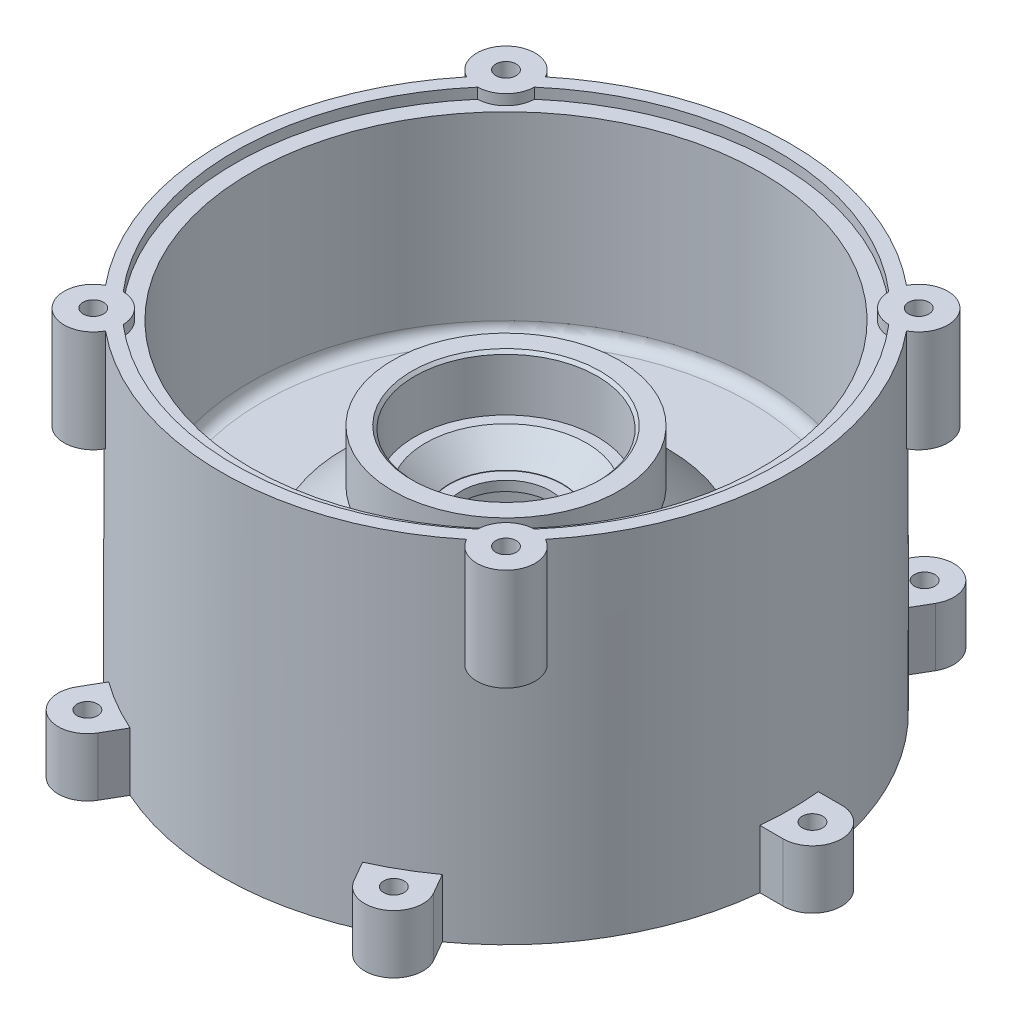
from build123d import *

# Parameters (mm, degrees)
ESBO_O4_R                = 10
RESSALTO_EXTRUS_O1_DEPTH = 35
RESSALTO_EXTRUS_O2_DEPTH = 20
ESBO_O8_R                = 3.5
CORTE_EXTRUS_O2_DEPTH    = 20
PADR_OCIRCULAR1_COUNT    = 6
ESBO_O6_R                = 3.5
CORTE_EXTRUS_O1_DEPTH    = 15
ESBO_O9_R                = 1.25
CORTE_EXTRUS_O3_DEPTH    = 6


with BuildPart() as part:
    # Esboço3 → Revolução2 (revolve)
    with BuildSketch(Plane.XY):
        with BuildLine():
            Line((97.5, 120), (97.5, 11.304491341))
            Line((97.5, 11.304491341), (97.5, 0))
            Line((97.5, 0), (82.842408243, 0))
            Line((82.842408243, 0), (60.342408243, 0))
            Line((60.342408243, 0), (60.342408243, 40))
            Line((60.342408243, 40), (52, 40))
            Line((52, 40), (44, 48))
            Line((44, 48), (31, 48))
            Line((31, 48), (31, 50.75))
            Line((31, 50.75), (22.6, 50.75))
            Line((22.6, 50.75), (22.6, 54.05))
            Line((22.6, 54.05), (19.3, 54.05))
            Line((19.3, 54.05), (19.3, 54.75))
            Line((19.3, 54.75), (15.3, 54.75))
            Line((15.3, 54.75), (15.3, 58.1))
            Line((15.3, 58.1), (19.3, 58.1))
            Line((19.3, 58.1), (19.3, 58.25))
            Line((19.3, 58.25), (27.626549127, 66.16))
            Line((27.626549127, 66.16), (31.3, 66.16))
            Line((31.3, 66.16), (31.3, 84.16))
            Line((31.3, 84.16), (32.3, 85.16))
            Line((32.3, 85.16), (38.8, 85.16))
            Line((38.8, 85.16), (38.8, 67.1))
            Line((38.8, 67.1), (55.5, 50.4))
            Line((55.5, 50.4), (83.5, 50.4))
            ThreePointArc((83.5, 50.4), (86.328427125, 51.571572875), (87.5, 54.4))
            Line((87.5, 54.4), (87.5, 116.4))
            Line((87.5, 116.4), (93, 116.4))
            Line((93, 116.4), (93, 120))
            Line((93, 120), (97.5, 120))
        make_face()
    revolve(axis=Axis((0, -3.631214097, 0), (0, 1, 0)))

    # Esboço4 → Ressalto-extrusão1 (add)
    with BuildSketch(Plane(origin=(0, 120, 0), x_dir=(1, 0, 0), z_dir=(0, 1, 0))):
        with Locations((70.71, 70.71)):
            Circle(ESBO_O4_R)
        with Locations((70.71, -70.71)):
            Circle(ESBO_O4_R)
        with Locations((-70.71, -70.71)):
            Circle(ESBO_O4_R)
        with Locations((-70.71, 70.71)):
            Circle(ESBO_O4_R)
    extrude(amount=-RESSALTO_EXTRUS_O1_DEPTH)

    # Esboço5 → Ressalto-extrusão2 (add)
    with BuildSketch(Plane.XZ):
        with BuildLine():
            Line((-105, -10), (-96.985823706, -10))
            Line((-96.985823706, -10), (-96.985823706, 10))
            Line((-96.985823706, 10), (-105, 10))
            ThreePointArc((-105, 10), (-115, 0), (-105, -10))
        make_face()
    ressalto_extrus_o2 = extrude(amount=-RESSALTO_EXTRUS_O2_DEPTH)

    # Esboço8 → Corte-extrusão2 (cut)
    with BuildSketch(Plane.XZ):
        with Locations((-105, 0)):
            Circle(ESBO_O8_R)
    corte_extrus_o2 = extrude(amount=-CORTE_EXTRUS_O2_DEPTH, mode=Mode.SUBTRACT)

    # PadrãoCircular1: Ressalto-extrusão2, Corte-extrusão2 ×6 about axis
    padr_ocircular1_axis = Axis((0, 0, 0), (0, 1, 0))
    for i in range(1, PADR_OCIRCULAR1_COUNT):
        add(ressalto_extrus_o2.rotate(padr_ocircular1_axis, i * 360 / PADR_OCIRCULAR1_COUNT))
        add(corte_extrus_o2.rotate(padr_ocircular1_axis, i * 360 / PADR_OCIRCULAR1_COUNT), mode=Mode.SUBTRACT)

    # Esboço6 → Corte-extrusão1 (cut)
    with BuildSketch(Plane(origin=(0, 120, 0), x_dir=(1, 0, 0), z_dir=(0, 1, 0))):
        with Locations((-70.71, -70.71)):
            Circle(ESBO_O6_R)
        with Locations((70.71, -70.71)):
            Circle(ESBO_O6_R)
        with Locations((70.71, 70.71)):
            Circle(ESBO_O6_R)
        with Locations((-70.71, 70.71)):
            Circle(ESBO_O6_R)
    extrude(amount=-CORTE_EXTRUS_O1_DEPTH, mode=Mode.SUBTRACT)

    # Esboço9 → Corte-extrusão3 (cut)
    with BuildSketch(Plane.XZ.offset(-50.75)):
        with Locations((0, 26.5)):
            Circle(ESBO_O9_R)
        with Locations((26.5, 0)):
            Circle(ESBO_O9_R)
        with Locations((0, -26.5)):
            Circle(ESBO_O9_R)
        with Locations((-26.5, 0)):
            Circle(ESBO_O9_R)
    extrude(amount=-CORTE_EXTRUS_O3_DEPTH, mode=Mode.SUBTRACT)


solid = part.part
